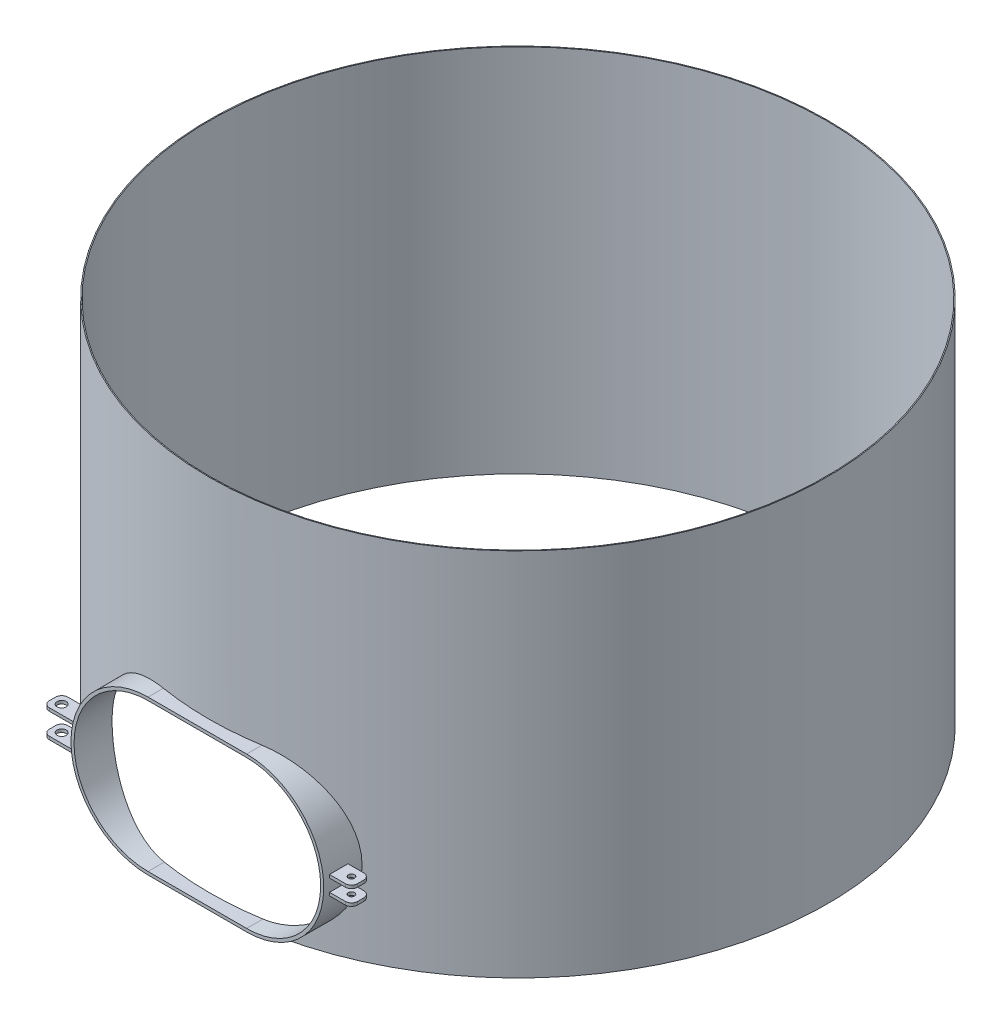
from build123d import *

# Parameters (mm, degrees)
SKETCH1_R           = 636.98374
SKETCH1_R_2         = 635
BOSS_EXTRUDE1_DEPTH = 762
BOSS_EXTRUDE2_DEPTH = 101.6
SKETCH5_R           = 635
CUT_EXTRUDE2_DEPTH  = 763.0000001
SKETCH7_W           = 38.1
SKETCH7_H           = 6.35
BOSS_EXTRUDE3_DEPTH = 101.6
SKETCH8_R           = 9.525
CUT_EXTRUDE3_DEPTH  = 76.2
FILLET1_R           = 12.7
SKETCH9_W           = 38.1
SKETCH9_H           = 6.35
BOSS_EXTRUDE4_DEPTH = 76.2
CUT_EXTRUDE1_DEPTH  = 101.6
SKETCH10_R          = 6.35
CUT_EXTRUDE4_DEPTH  = 188.9600001
FILLET2_R           = 12.7


with BuildPart() as part:
    # Sketch1 → Boss-Extrude1 (new body)
    with BuildSketch(Plane(origin=(0, 0, 0), x_dir=(1, 0, 0), z_dir=(0, 1, 0))):
        with Locations(Location((0, 0, 0), (0, 0, 270))):  # turned: the seam where the file's is
            Circle(SKETCH1_R)
        with Locations(Location((0, 0, 0), (0, 0, 270))):  # turned: the seam where the file's is
            Circle(SKETCH1_R_2, mode=Mode.SUBTRACT)
    extrude(amount=BOSS_EXTRUDE1_DEPTH)

    # Sketch3 → Boss-Extrude2 (add)
    with BuildSketch(Plane(origin=(0, -431.8, 558.8), x_dir=(1, 0, 0), z_dir=(0, 0, -1))):
        with BuildLine():
            Line((-101.6, -444.5), (101.6, -444.5))
            ThreePointArc((101.6, -444.5), (260.35, -603.25), (101.6, -762))
            Line((101.6, -762), (-101.6, -762))
            ThreePointArc((-101.6, -762), (-260.35, -603.25), (-101.6, -444.5))
        make_face()
        with BuildLine():
            Line((-101.6, -450.85), (101.6, -450.85))
            ThreePointArc((101.6, -450.85), (254, -603.25), (101.6, -755.65))
            Line((101.6, -755.65), (-101.6, -755.65))
            ThreePointArc((-101.6, -755.65), (-254, -603.25), (-101.6, -450.85))
        make_face(mode=Mode.SUBTRACT)
    extrude(amount=-BOSS_EXTRUDE2_DEPTH)

    # Sketch5 → Cut-Extrude2 (cut, through all)
    with BuildSketch(Plane(origin=(0, 762, 0), x_dir=(1, 0, 0), z_dir=(0, 1, 0))):
        with Locations(Location((0, 0, 0), (0, 0, 270))):  # turned: the seam where the file's is
            Circle(SKETCH5_R)
    extrude(amount=-CUT_EXTRUDE2_DEPTH, mode=Mode.SUBTRACT)

    # Sketch7 → Boss-Extrude3 (add)
    with BuildSketch(Plane(origin=(-228.6, 0, 0), x_dir=(0, 0, -1), z_dir=(1, 0, 0))):
        with Locations((-628.65, 193.675)):
            Rectangle(SKETCH7_W, SKETCH7_H)
        with Locations((-628.65, 142.875)):
            Rectangle(SKETCH7_W, SKETCH7_H)
    extrude(amount=-BOSS_EXTRUDE3_DEPTH)

    # Sketch8 → Cut-Extrude3 (cut)
    with BuildSketch(Plane(origin=(0, 196.85, 0), x_dir=(1, 0, 0), z_dir=(0, 1, 0))):
        with Locations(Location((-311.15, -628.65, 0), (0, 0, 270))):  # turned: the seam where the file's is
            Circle(SKETCH8_R)
    extrude(amount=-CUT_EXTRUDE3_DEPTH, mode=Mode.SUBTRACT)

    # Fillet1
    fillet1_edges = [part.edges().sort_by_distance(p)[0] for p in [
        (-330.2, 193.675, 609.6),
        (-330.2, 193.675, 647.7),
        (-330.2, 142.875, 609.6),
        (-330.2, 142.875, 647.7),
    ]]
    fillet(fillet1_edges, radius=FILLET1_R)

    # Sketch9 → Boss-Extrude4 (add)
    with BuildSketch(Plane(origin=(228.6, 0, 0), x_dir=(0, 0, -1), z_dir=(1, 0, 0))):
        with Locations((-628.65, 184.785)):
            Rectangle(SKETCH9_W, SKETCH9_H)
        with Locations((-628.65, 153.035)):
            Rectangle(SKETCH9_W, SKETCH9_H)
    extrude(amount=BOSS_EXTRUDE4_DEPTH)

    # Sketch4 → Cut-Extrude1 (cut)
    with BuildSketch(Plane.XY.offset(660.4)):
        with BuildLine():
            Line((-101.6, 323.85), (101.6, 323.85))
            ThreePointArc((101.6, 323.85), (254, 171.45), (101.6, 19.05))
            Line((101.6, 19.05), (-101.6, 19.05))
            ThreePointArc((-101.6, 19.05), (-254, 171.45), (-101.6, 323.85))
        make_face()
    extrude(amount=-CUT_EXTRUDE1_DEPTH, mode=Mode.SUBTRACT)

    # Sketch10 → Cut-Extrude4 (cut, through all)
    with BuildSketch(Plane(origin=(0, 187.96, 0), x_dir=(1, 0, 0), z_dir=(0, 1, 0))):
        with Locations(Location((285.75, -628.65, 0), (0, 0, 270))):  # turned: the seam where the file's is
            Circle(SKETCH10_R)
    extrude(amount=-CUT_EXTRUDE4_DEPTH, mode=Mode.SUBTRACT)

    # Fillet2
    fillet2_edges = [part.edges().sort_by_distance(p)[0] for p in [
        (304.8, 184.785, 647.7),
        (304.8, 184.785, 609.6),
        (304.8, 153.035, 647.7),
        (304.8, 153.035, 609.6),
    ]]
    fillet(fillet2_edges, radius=FILLET2_R)


solid = part.part
